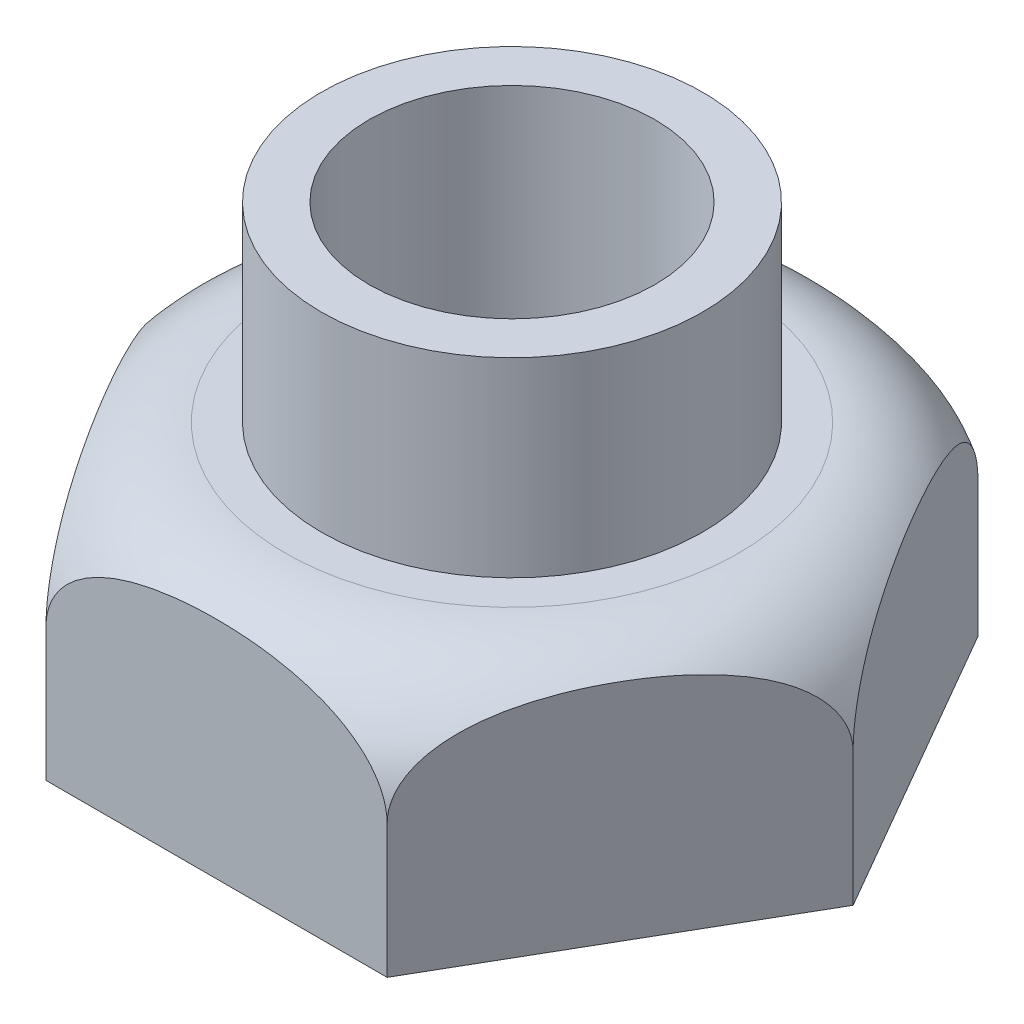
from build123d import *

# Parameters (mm, degrees)
BOSS_EXTRUDE1_DEPTH     = 65
BOSS_EXTRUDE3_START     = 65
SKETCH4_R               = 50
BOSS_EXTRUDE3_DEPTH     = 50
SKETCH6_R               = 37.5
CUT_EXTRUDE1_DEPTH      = 116
CUT_EXTRUDE1_DEPTH_BACK = 1


with BuildPart() as part:
    # Sketch1 → Boss-Extrude1 (new body)
    with BuildSketch(Plane(origin=(0, 0, 0), x_dir=(1, 0, 0), z_dir=(0, 1, 0))):
        Polygon((89.489291724, 0), (44.744645862, 77.5), (-44.744645862, 77.5), (-89.489291724, 0), (-44.744645862, -77.5), (44.744645862, -77.5), align=None)
    extrude(amount=BOSS_EXTRUDE1_DEPTH)

    # Sketch4 → Boss-Extrude3 (add)
    with BuildSketch(Plane(origin=(0, 0, 0), x_dir=(1, 0, 0), z_dir=(0, 1, 0)).offset(BOSS_EXTRUDE3_START)):
        Circle(SKETCH4_R)
    extrude(amount=BOSS_EXTRUDE3_DEPTH)

    # Sketch6 → Cut-Extrude1 (cut, two sides)
    with BuildSketch(Plane(origin=(0, 0, 0), x_dir=(1, 0, 0), z_dir=(0, 1, 0))) as cut_extrude1_sk:
        Circle(SKETCH6_R)
    extrude(amount=CUT_EXTRUDE1_DEPTH, mode=Mode.SUBTRACT)
    extrude(cut_extrude1_sk.sketch, amount=-CUT_EXTRUDE1_DEPTH_BACK, mode=Mode.SUBTRACT)

    # Sketch7 → Cut-Revolve1 (revolve, cut)
    with BuildSketch(Plane.XY):
        with BuildLine():
            Line((89.489291724, 35), (89.489291724, 65))
            Line((89.489291724, 65), (59.489291724, 65))
            ThreePointArc((59.489291724, 65), (80.70249516, 56.213203436), (89.489291724, 35))
        make_face()
    revolve(axis=Axis((0, 0, 0), (0, 1, 0)), mode=Mode.SUBTRACT)


solid = part.part
